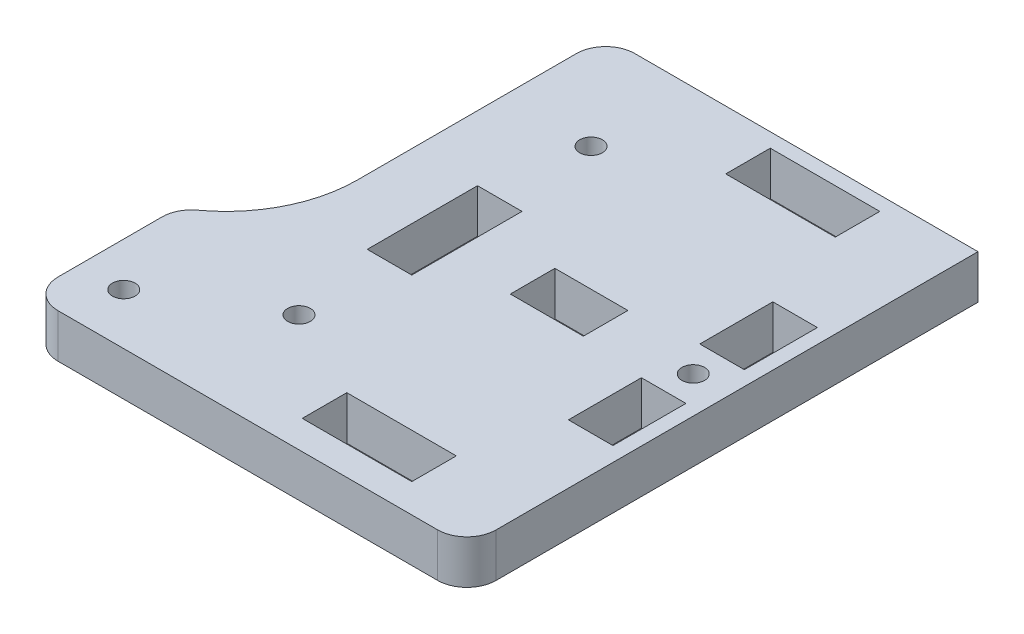
from build123d import *

# Parameters (mm, degrees)
SKETCH_1_R      = 1.55
SKETCH_1_W      = 6.1
SKETCH_1_H      = 10
SKETCH_1_H_2    = 15.1
SKETCH_1_W_2    = 10
SKETCH_1_H_3    = 6.1
SKETCH_1_W_3    = 15
EXTRUDE_1_DEPTH = 6


with BuildPart() as part:
    # Эскиз1 → Бобышка-Вытянуть1 (new body)
    with BuildSketch(Plane(origin=(0, 0, 0), x_dir=(1, 0, 0), z_dir=(0, 1, 0))):
        with BuildLine():
            Line((-35.752327672, -33.813906094), (16.247672328, -33.813906094))
            ThreePointArc((16.247672328, -33.813906094), (19.076099452, -32.642333219), (20.247672328, -29.813906094))
            Line((20.247672328, -29.813906094), (20.247672328, 36.186093906))
            Line((20.247672328, 36.186093906), (-26.752327672, 36.186093906))
            ThreePointArc((-26.752327672, 36.186093906), (-29.580754797, 35.014521031), (-30.752327672, 32.186093906))
            Line((-30.752327672, 32.186093906), (-30.752327672, 2.186093906))
            ThreePointArc((-30.752327672, 2.186093906), (-32.698441142, -5.954712398), (-38.115964036, -12.335192834))
            ThreePointArc((-38.115964036, -12.335192834), (-39.319858012, -13.753077376), (-39.752327672, -15.562145443))
            Line((-39.752327672, -15.562145443), (-39.752327672, -29.813906094))
            ThreePointArc((-39.752327672, -29.813906094), (-38.580754797, -32.642333219), (-35.752327672, -33.813906094))
        make_face()
        with Locations((15.247672328, 2.186093906)):
            Circle(SKETCH_1_R, mode=Mode.SUBTRACT)
        with Locations((-18.752327672, -17.813906094)):
            Circle(SKETCH_1_R, mode=Mode.SUBTRACT)
        with Locations((-33.752327672, -26.813906094)):
            Circle(SKETCH_1_R, mode=Mode.SUBTRACT)
        with Locations((-18.752327672, 22.186093906)):
            Circle(SKETCH_1_R, mode=Mode.SUBTRACT)
        with Locations((15.197672328, 11.186093906)):
            Rectangle(SKETCH_1_W, SKETCH_1_H, mode=Mode.SUBTRACT)
        with Locations((-18.802327672, 2.186093906)):
            Rectangle(SKETCH_1_W, SKETCH_1_H_2, mode=Mode.SUBTRACT)
        with Locations((-1.752327672, 2.186093906)):
            Rectangle(SKETCH_1_W_2, SKETCH_1_H_3, mode=Mode.SUBTRACT)
        with Locations((15.197672328, -6.813906094)):
            Rectangle(SKETCH_1_W, SKETCH_1_H, mode=Mode.SUBTRACT)
        with Locations((1.247672328, 31.186093906)):
            Rectangle(SKETCH_1_W_3, SKETCH_1_H_3, mode=Mode.SUBTRACT)
        with Locations((1.247672328, -26.813906094)):
            Rectangle(SKETCH_1_W_3, SKETCH_1_H_3, mode=Mode.SUBTRACT)
    extrude(amount=EXTRUDE_1_DEPTH)


solid = part.part
